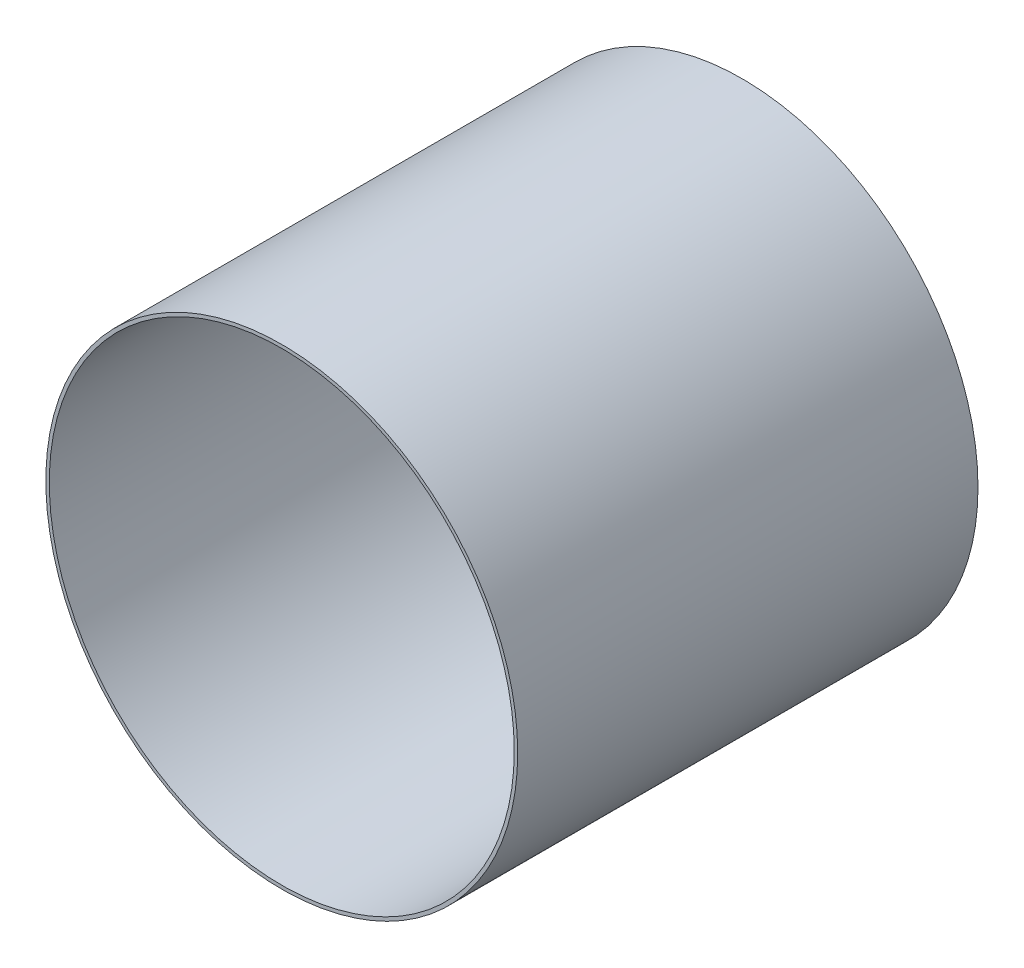
from build123d import *

# Parameters (mm, degrees)
SCHIZZO1_R                   = 500
SCHIZZO1_R_2                 = 492.7
ESTRUSIONE_ESTRUSIONE1_DEPTH = 975.5


with BuildPart() as part:
    # Schizzo1 → Estrusione-Estrusione1 (new body)
    with BuildSketch(Plane.XY):
        Circle(SCHIZZO1_R)
        Circle(SCHIZZO1_R_2, mode=Mode.SUBTRACT)
    extrude(amount=ESTRUSIONE_ESTRUSIONE1_DEPTH)


solid = part.part
